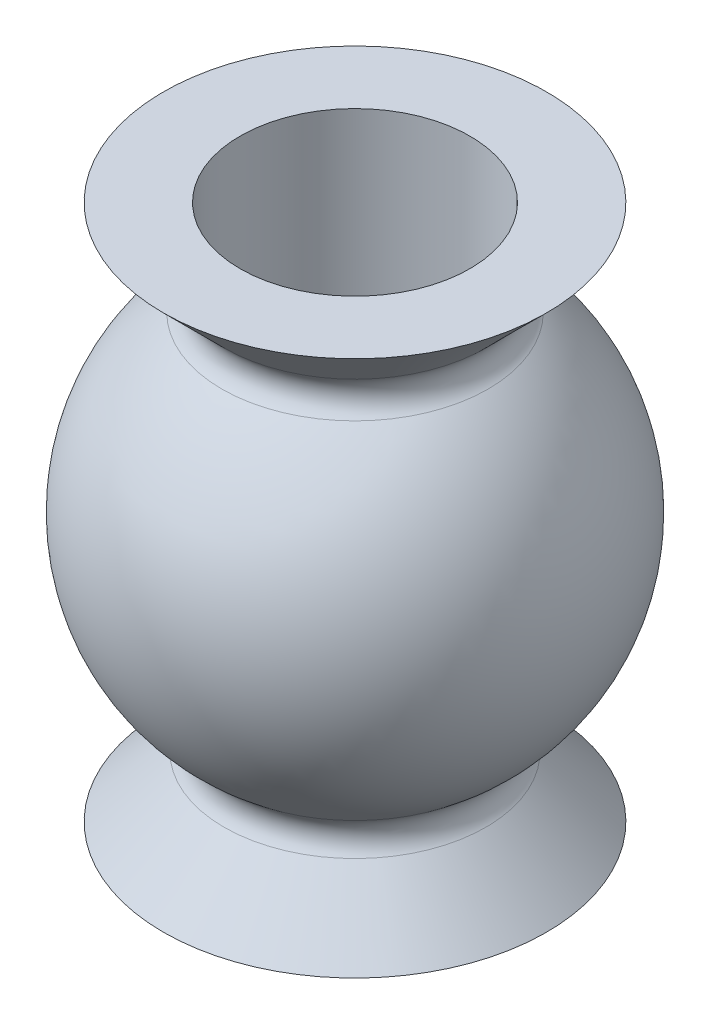
from build123d import *


with BuildPart() as part:
    # Эскиз1 → Повернуть1 (revolve)
    with BuildSketch(Plane(origin=(0, 0, 0), x_dir=(0, 0, -1), z_dir=(1, 0, 0))):
        with BuildLine():
            Line((2.5, 3.5), (1.5, 3.5))
            Line((1.5, 3.5), (1.5, -3.5))
            Line((1.5, -3.5), (2.5, -3.5))
            Line((2.5, -3.5), (1.708705964, -2.708705964))
            ThreePointArc((1.708705964, -2.708705964), (1.621467661, -2.477147118), (1.737901046, -2.258804984))
            ThreePointArc((1.737901046, -2.258804984), (2.85, 0), (1.737901046, 2.258804984))
            ThreePointArc((1.737901046, 2.258804984), (1.621467661, 2.477147118), (1.708705964, 2.708705964))
            Line((1.708705964, 2.708705964), (2.5, 3.5))
        make_face()
    revolve(axis=Axis((0, 0, 0), (0, -1, 0)))


solid = part.part
